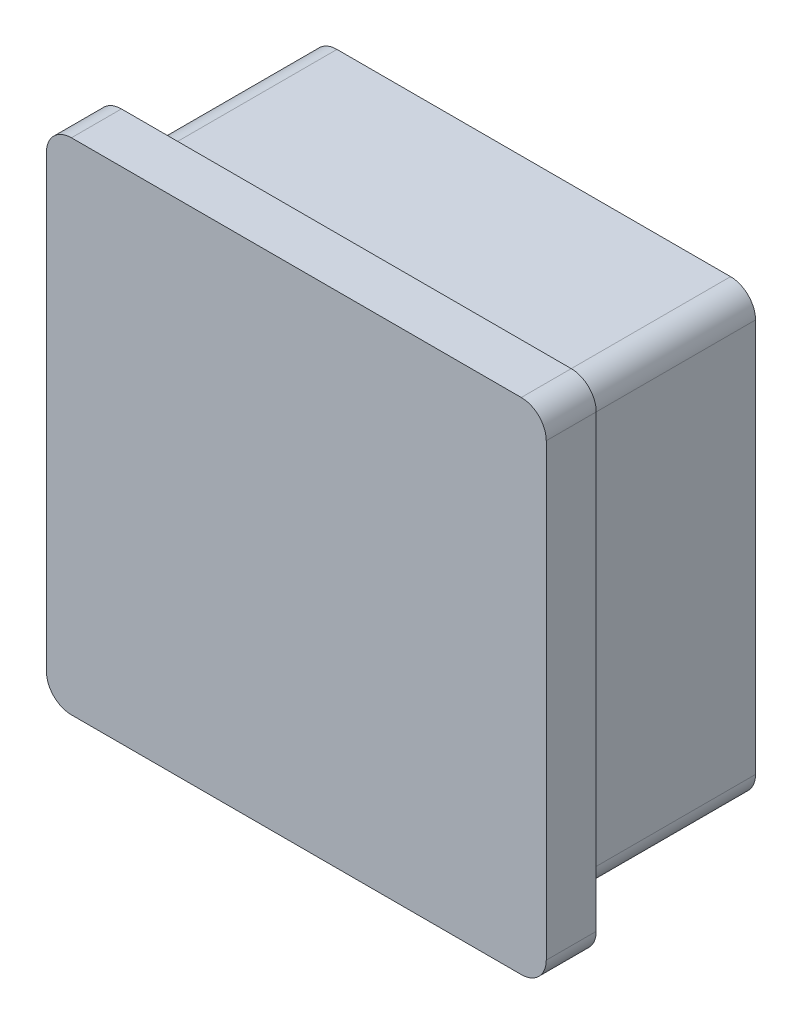
from build123d import *

# Parameters (mm, degrees)
P_IDAT_VYSUNUT_M1_DEPTH = 4
SKICA2_W                = 30.5
SKICA2_H                = 30.5
SKICA2_W_2              = 4
SKICA2_H_2              = 4
P_IDAT_VYSUNUT_M2_DEPTH = 15


with BuildPart() as part:
    # Skica1 → Přidat vysunutím1 (new body)
    with BuildSketch(Plane.XY):
        with BuildLine():
            Line((-18, 20), (18, 20))
            ThreePointArc((18, 20), (19.414213562, 19.414213562), (20, 18))
            Line((20, 18), (20, -18))
            ThreePointArc((20, -18), (19.414213562, -19.414213562), (18, -20))
            Line((18, -20), (-18, -20))
            ThreePointArc((-18, -20), (-19.414213562, -19.414213562), (-20, -18))
            Line((-20, -18), (-20, 18))
            ThreePointArc((-20, 18), (-19.414213562, 19.414213562), (-18, 20))
        make_face()
    extrude(amount=P_IDAT_VYSUNUT_M1_DEPTH)

    # Skica2 → Přidat vysunutím2 (add)
    with BuildSketch(Plane(origin=(0, 0, 0), x_dir=(-1, 0, 0), z_dir=(0, 0, -1))):
        with BuildLine():
            ThreePointArc((-17.75, 15.75), (-17.164213562, 17.164213562), (-15.75, 17.75))
            Line((-15.75, 17.75), (15.75, 17.75))
            ThreePointArc((15.75, 17.75), (17.164213562, 17.164213562), (17.75, 15.75))
            Line((17.75, 15.75), (17.75, -15.75))
            ThreePointArc((17.75, -15.75), (17.164213562, -17.164213562), (15.75, -17.75))
            Line((15.75, -17.75), (-15.75, -17.75))
            ThreePointArc((-15.75, -17.75), (-17.164213562, -17.164213562), (-17.75, -15.75))
            Line((-17.75, -15.75), (-17.75, 15.75))
        make_face()
        Rectangle(SKICA2_W, SKICA2_H, mode=Mode.SUBTRACT)
        with Locations((-2, 13.25)):
            Rectangle(SKICA2_W_2, SKICA2_H_2)
        with Locations((2, 13.25)):
            Rectangle(SKICA2_W_2, SKICA2_H_2)
        with Locations((13.25, 2)):
            Rectangle(SKICA2_W_2, SKICA2_H_2)
        with Locations((13.25, -2)):
            Rectangle(SKICA2_W_2, SKICA2_H_2)
        with Locations((2, -13.25)):
            Rectangle(SKICA2_W_2, SKICA2_H_2)
        with Locations((-2, -13.25)):
            Rectangle(SKICA2_W_2, SKICA2_H_2)
        with Locations((-13.25, 2)):
            Rectangle(SKICA2_W_2, SKICA2_H_2)
        with Locations((-13.25, -2)):
            Rectangle(SKICA2_W_2, SKICA2_H_2)
    extrude(amount=P_IDAT_VYSUNUT_M2_DEPTH)


solid = part.part
